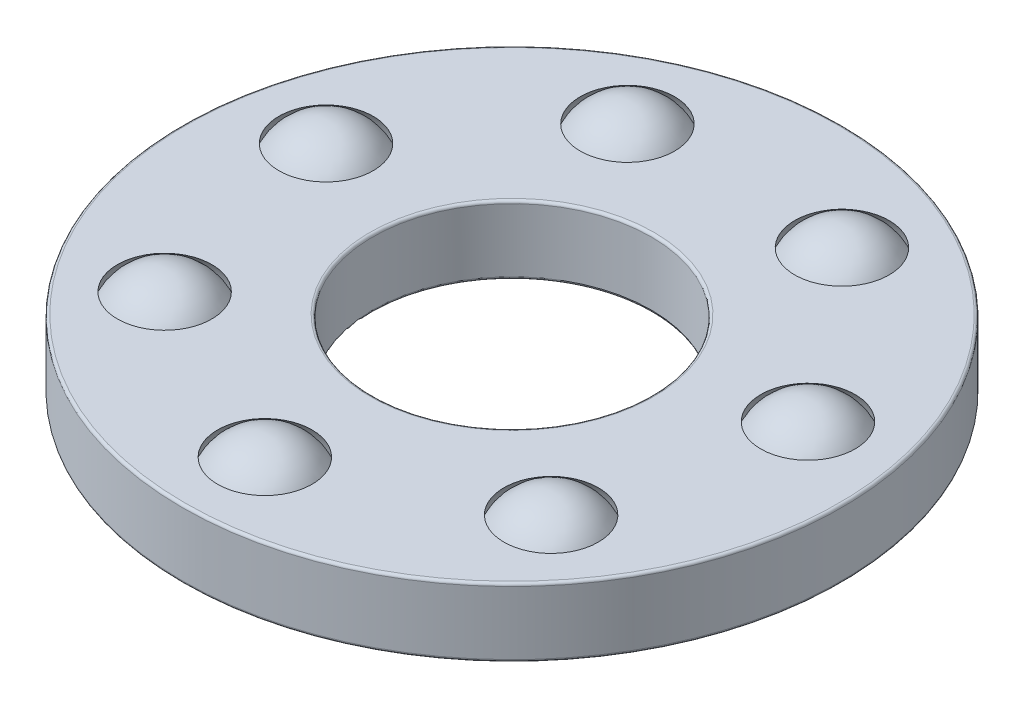
from build123d import *

# Parameters (mm, degrees)
SKETCH1_W         = 3.462
SKETCH1_H         = 1.25
CIRPATTERN1_COUNT = 7
CIRPATTERN1_ANGLE = 308.571428571
CIRPATTERN2_COUNT = 7
SKETCH4_W         = 3.462
SKETCH4_H         = 1.46
FILLET1_R         = 0.0492
FILLET2_R         = 0.0492
FILLET3_R         = 0.0492


with BuildPart() as part:
    # Sketch1 → Revolve1 (revolve)
    with BuildSketch(Plane(origin=(0, 0, 0), x_dir=(0, 0, -1), z_dir=(1, 0, 0))):
        with Locations((-4.269, 0)):
            Rectangle(SKETCH1_W, SKETCH1_H)
    revolve(axis=Axis((0, -2.46, 0), (0, 1, 0)))

    # Sketch3 → Cut-Revolve1 (revolve, cut)
    with BuildSketch(Plane(origin=(0, 0, 0), x_dir=(0, 0, -1), z_dir=(1, 0, 0))):
        with BuildLine():
            Line((-4.5, 1.0625), (-4.5, -1.0625))
            ThreePointArc((-4.5, -1.0625), (-5.5625, 0), (-4.5, 1.0625))
        make_face()
    cut_revolve1 = revolve(axis=Axis((0, 1.0625, 4.5), (0, -1, 0)), mode=Mode.SUBTRACT)

    # CirPattern2: Cut-Revolve1 ×7 about axis
    cirpattern2_axis = Axis((0, 0, 0), (0, 1, 0))
    for i in range(1, CIRPATTERN2_COUNT):
        add(cut_revolve1.rotate(cirpattern2_axis, i * 360 / CIRPATTERN2_COUNT), mode=Mode.SUBTRACT)

    # Fillet2
    fillet2_edges = [part.edges().sort_by_distance(p)[0] for p in [
        (0, 0.625, -6),
        (0, 0.625, -2.538),
        (0, -0.625, -2.538),
        (0, -0.625, -6),
    ]]
    fillet(fillet2_edges, radius=FILLET2_R)


with BuildPart() as body_2:
    # Sketch2 → Revolve2 (revolve)
    with BuildSketch(Plane(origin=(0, 0, 0), x_dir=(0, 0, -1), z_dir=(1, 0, 0))):
        with BuildLine():
            Line((-4.5, 1), (-4.5, -1))
            ThreePointArc((-4.5, -1), (-5.5, 0), (-4.5, 1))
        make_face()
    revolve(axis=Axis((0, 1, 4.5), (0, -1, 0)))


with BuildPart() as cirpattern1_1:
    # CirPattern1: pattern copy
    add(body_2.part.rotate(Axis((0, 2.46, 0), (0, -1, 0)), 1 * CIRPATTERN1_ANGLE / (CIRPATTERN1_COUNT - 1)))


with BuildPart() as cirpattern1_2:
    # CirPattern1: pattern copy
    add(body_2.part.rotate(Axis((0, 2.46, 0), (0, -1, 0)), 2 * CIRPATTERN1_ANGLE / (CIRPATTERN1_COUNT - 1)))


with BuildPart() as cirpattern1_3:
    # CirPattern1: pattern copy
    add(body_2.part.rotate(Axis((0, 2.46, 0), (0, -1, 0)), 3 * CIRPATTERN1_ANGLE / (CIRPATTERN1_COUNT - 1)))


with BuildPart() as cirpattern1_4:
    # CirPattern1: pattern copy
    add(body_2.part.rotate(Axis((0, 2.46, 0), (0, -1, 0)), 4 * CIRPATTERN1_ANGLE / (CIRPATTERN1_COUNT - 1)))


with BuildPart() as cirpattern1_5:
    # CirPattern1: pattern copy
    add(body_2.part.rotate(Axis((0, 2.46, 0), (0, -1, 0)), 5 * CIRPATTERN1_ANGLE / (CIRPATTERN1_COUNT - 1)))


with BuildPart() as cirpattern1_6:
    # CirPattern1: pattern copy
    add(body_2.part.rotate(Axis((0, 2.46, 0), (0, -1, 0)), 6 * CIRPATTERN1_ANGLE / (CIRPATTERN1_COUNT - 1)))


with BuildPart() as body_9:
    # Sketch4 → Revolve3 (revolve)
    with BuildSketch(Plane(origin=(0, 0, 0), x_dir=(0, 0, -1), z_dir=(1, 0, 0))):
        with Locations((-4.269, 1.73)):
            Rectangle(SKETCH4_W, SKETCH4_H)
        with Locations((-4.269, -1.73)):
            Rectangle(SKETCH4_W, SKETCH4_H)
    revolve(axis=Axis((0, -2.46, 0), (0, 1, 0)))

    # Fillet1
    fillet1_edges = [body_9.edges().sort_by_distance(p)[0] for p in [
        (0, 1, -6),
        (0, 1, -2.538),
        (0, 2.46, -2.538),
        (0, 2.46, -6),
    ]]
    fillet(fillet1_edges, radius=FILLET1_R)

    # Fillet3
    fillet3_edges = [body_9.edges().sort_by_distance(p)[0] for p in [
        (0, -2.46, -6),
        (0, -2.46, -2.538),
        (0, -1, -2.538),
        (0, -1, -6),
    ]]
    fillet(fillet3_edges, radius=FILLET3_R)


solid = Compound([part.part, body_2.part, cirpattern1_1.part, cirpattern1_2.part, cirpattern1_3.part, cirpattern1_4.part, cirpattern1_5.part, cirpattern1_6.part])
